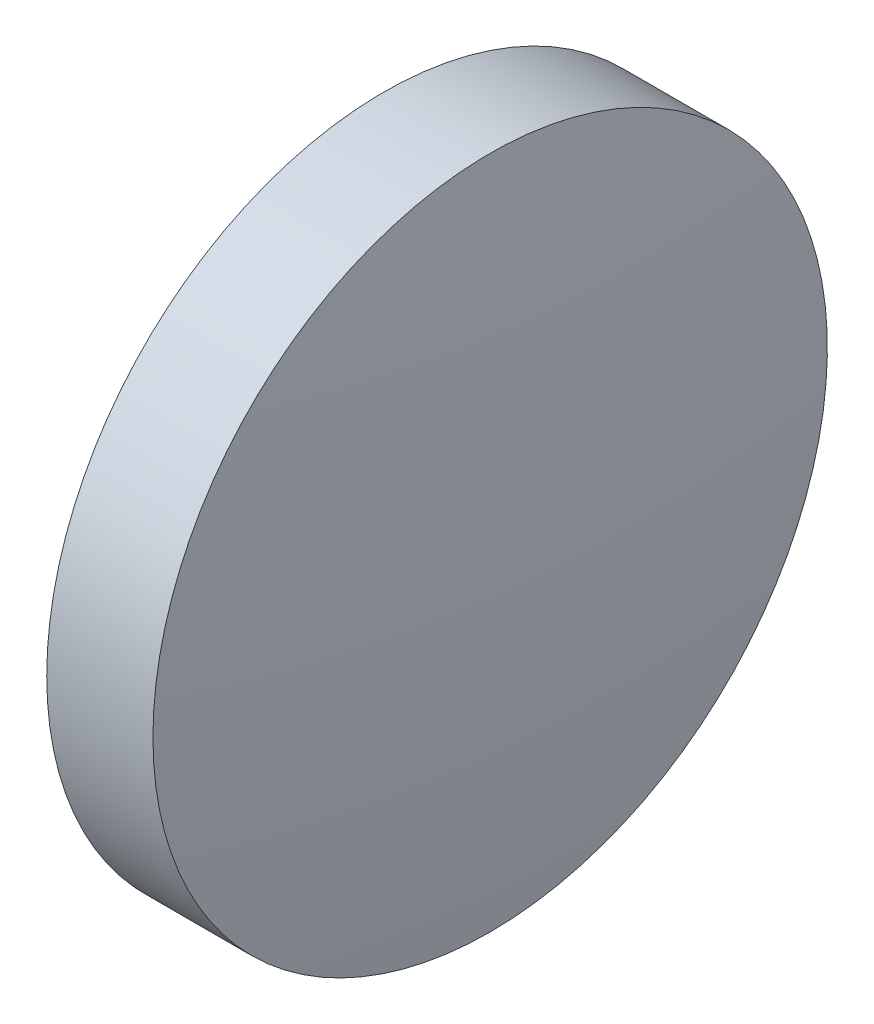
from build123d import *


with BuildPart() as part:
    # 草图1 → 旋转1 (revolve)
    with BuildSketch(Plane.XY, mode=Mode.PRIVATE) as revolve_1_sk:
        with BuildLine():
            Line((459.761244984, 237.484622243), (459.761244984, 243.834622243))
            Line((459.761244984, 243.834622243), (461.761244984, 243.834622243))
            ThreePointArc((461.761244984, 243.834622243), (462.06114598, 240.665915219), (462.161244984, 237.484622243))
            Line((462.161244984, 237.484622243), (459.761244984, 237.484622243))
        make_face()
    revolve(revolve_1_sk.sketch.rotate(Axis((457.500713839, 237.484622243, 0), (1, 0, 0)), 180), axis=Axis((457.500713839, 237.484622243, 0), (1, 0, 0)))  # turned: the seam where the file's is


solid = part.part
